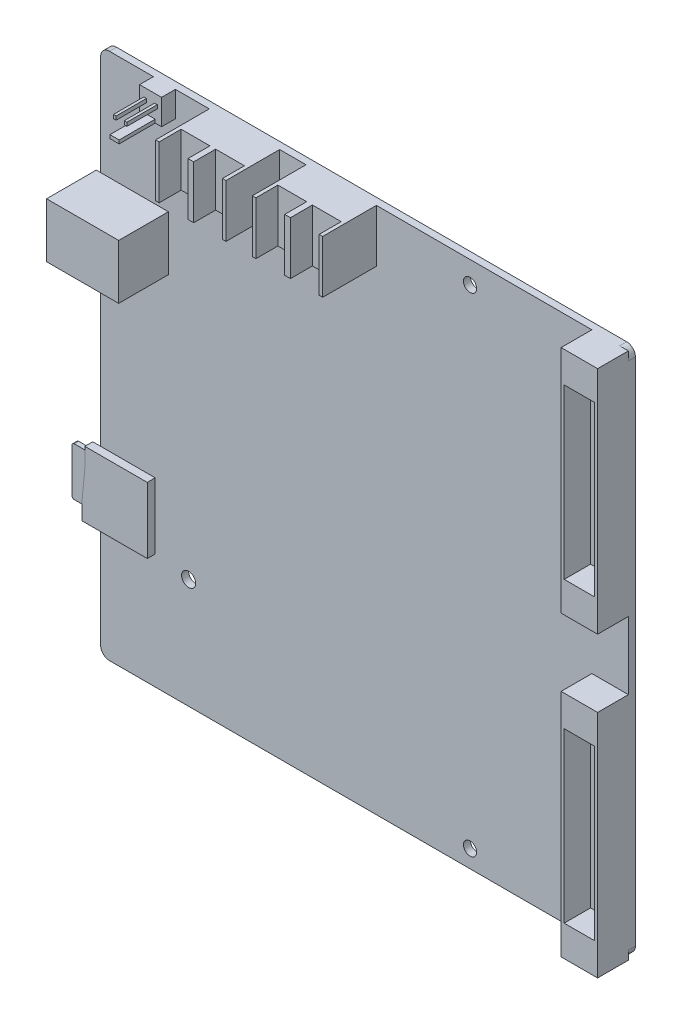
from build123d import *

# Parameters (mm, degrees)
SKETCH_1_R             = 1.5
EXTRUDE_1_DEPTH        = 1.6
SKETCH_2_W             = 16.4
SKETCH_2_H             = 12.4
EXTRUDE_2_DEPTH        = 11.3
SKETCH_3_W             = 3
SKETCH_3_H             = 5.4
CUT_EXTRUDE_1_DEPTH    = 9
EXTRUDE_3_DEPTH        = 1.8
SKETCH_5_W             = 1
SKETCH_5_H             = 11
EXTRUDE_4_DEPTH        = 3
FILLET_1_R             = 0.5
SKETCH_43_W            = 8.3
SKETCH_43_H            = 52.3
EXTRUDE_15_DEPTH       = 7
SKETCH_45_W            = 6.9
SKETCH_45_H            = 38.3
CUT_EXTRUDE_12_DEPTH   = 6
SKETCH_53_W            = 16
SKETCH_53_H            = 12
EXTRUDE_20_DEPTH       = 12.2
SKETCH_54_W            = 6.55
SKETCH_54_H            = 12
CUT_EXTRUDE_14_DEPTH   = 5
SKETCH_59_R            = 1.6
CUT_EXTRUDE_16_DEPTH   = 10
PATTERN_LINEAR_4_COUNT = 2
PATTERN_LINEAR_4_PITCH = 22
SKETCH_60_W            = 5
SKETCH_60_H            = 5.8
EXTRUDE_21_DEPTH       = 3.15
SKETCH_61_W            = 2.1
SKETCH_61_H            = 0.78
EXTRUDE_22_DEPTH       = 8.2
EXTRUDE_23_DEPTH       = 6.9
EXTRUDE_23_DEPTH_BACK  = 6
SKETCH_62_W            = 0.6
SKETCH_62_H            = 0.835930121


with BuildPart() as part:
    # 草图1 → 凸台-拉伸1 (new body)
    with BuildSketch(Plane.XY):
        with BuildLine():
            Line((58, -60), (-58, -60))
            ThreePointArc((-58, -60), (-59.414213562, -59.414213562), (-60, -58))
            Line((-60, -58), (-60, 58))
            ThreePointArc((-60, 58), (-59.414213562, 59.414213562), (-58, 60))
            Line((-58, 60), (58, 60))
            ThreePointArc((58, 60), (59.414213562, 59.414213562), (60, 58))
            Line((60, 58), (60, -58))
            ThreePointArc((60, -58), (59.414213562, -59.414213562), (58, -60))
        make_face()
        with Locations((24, 55)):
            Circle(SKETCH_1_R, mode=Mode.SUBTRACT)
        with Locations((24, -56)):
            Circle(SKETCH_1_R, mode=Mode.SUBTRACT)
    extrude(amount=EXTRUDE_1_DEPTH)

    # 草图2 → 凸台-拉伸2 (add)
    with BuildSketch(Plane.XY.offset(1.6)):
        with Locations((-52.8, 28.9)):
            Rectangle(SKETCH_2_W, SKETCH_2_H)
    extrude(amount=EXTRUDE_2_DEPTH)

    # 草图3 → 切除-拉伸1 (cut)
    with BuildSketch(Plane.ZY.offset(61)):
        Polygon((3, 33.7), (3, 24.1), (9.9, 24.1), (11.5, 25.7), (11.5, 32.1), (9.9, 33.7), align=None)
        with Locations((6.9, 28.9)):
            Rectangle(SKETCH_3_W, SKETCH_3_H, mode=Mode.SUBTRACT)
    extrude(amount=-CUT_EXTRUDE_1_DEPTH, mode=Mode.SUBTRACT)

    # 草图4 → 凸台-拉伸3 (add)
    with BuildSketch(Plane.XY.offset(1.6)):
        Polygon((-47.6, -18.8), (-47.6, -33.8), (-62.4, -33.8), (-62.4, -29.5), (-61.8, -23.188583942), (-61.8, -18.8), align=None)
    extrude(amount=EXTRUDE_3_DEPTH)

    # 草图5 → 凸台-拉伸4 (add)
    with BuildSketch(Plane.ZY.offset(61.8)):
        with Locations((2.8, -25.1)):
            Rectangle(SKETCH_5_W, SKETCH_5_H)
    extrude(amount=EXTRUDE_4_DEPTH)

    # 圆角1
    fillet_1_edges = [part.edges().sort_by_distance(p)[0] for p in [
        (-64.8, -19.6, 2.8),
        (-64.8, -30.6, 2.8),
    ]]
    fillet(fillet_1_edges, radius=FILLET_1_R)

    # 草图43 → 凸台-拉伸15 (add)
    with BuildSketch(Plane(origin=(66.890855613, 85.562649537, 1.6), x_dir=(1, 0, 0), z_dir=(0, 0, 1))):
        with Locations((-11.040855613, -51.712649537)):
            Rectangle(SKETCH_43_W, SKETCH_43_H)
        with Locations((-11.040855613, -119.412649537)):
            Rectangle(SKETCH_43_W, SKETCH_43_H)
    extrude(amount=EXTRUDE_15_DEPTH)

    # 草图45 → 切除-拉伸12 (cut)
    with BuildSketch(Plane(origin=(66.890855613, 85.562649537, 8.6), x_dir=(1, 0, 0), z_dir=(0, 0, 1))):
        with Locations((-11.040855613, -51.712649537)):
            Rectangle(SKETCH_45_W, SKETCH_45_H)
        with Locations((-11.040855613, -119.412649537)):
            Rectangle(SKETCH_45_W, SKETCH_45_H)
    extrude(amount=-CUT_EXTRUDE_12_DEPTH, mode=Mode.SUBTRACT)

    # 草图53 → 凸台-拉伸20 (add)
    with BuildSketch(Plane.XY.offset(1.6)):
        with Locations((-5.3, 54)):
            Rectangle(SKETCH_53_W, SKETCH_53_H)
    extrude_20 = extrude(amount=EXTRUDE_20_DEPTH)

    # 草图54 → 切除-拉伸14 (cut)
    with BuildSketch(Plane.XY.offset(13.8)):
        with Locations((-9.225, 54)):
            Rectangle(SKETCH_54_W, SKETCH_54_H)
        with Locations((-1.375, 54)):
            Rectangle(SKETCH_54_W, SKETCH_54_H)
    cut_extrude_14 = extrude(amount=-CUT_EXTRUDE_14_DEPTH, mode=Mode.SUBTRACT)

    # 草图59 → 切除-拉伸16 (cut)
    with BuildSketch(Plane.XY.offset(1.6)):
        with Locations((-40, -35)):
            Circle(SKETCH_59_R)
        with Locations((-40, 45)):
            Circle(SKETCH_59_R)
    extrude(amount=-CUT_EXTRUDE_16_DEPTH, mode=Mode.SUBTRACT)

    # 阵列(线性)4: 凸台-拉伸20, 切除-拉伸14 ×2
    with Locations(*[(-i * PATTERN_LINEAR_4_PITCH, 0, 0) for i in range(1, PATTERN_LINEAR_4_COUNT)]):
        add(extrude_20)
        add(cut_extrude_14, mode=Mode.SUBTRACT)

    # 草图60 → 凸台-拉伸21 (add)
    with BuildSketch(Plane.XY.offset(1.6)):
        with Locations((-45.5, 57.1)):
            Rectangle(SKETCH_60_W, SKETCH_60_H)
    extrude(amount=EXTRUDE_21_DEPTH)

    # 草图61 → 凸台-拉伸22 (add)
    with BuildSketch(Plane.XY.offset(4.75)):
        with Locations((-45.5, 54.59)):
            Rectangle(SKETCH_61_W, SKETCH_61_H)
    extrude(amount=EXTRUDE_22_DEPTH)

    # 草图62 → 凸台-拉伸23 (add, two sides: drawn at the far end of the back side and taken through both)
    with BuildSketch(Plane.XY.offset(4.75).offset(-EXTRUDE_23_DEPTH_BACK)):
        with Locations((-44.275, 57.657035773)):
            Rectangle(SKETCH_62_W, SKETCH_62_H)
        with Locations((-46.725, 57.657035773)):
            Rectangle(SKETCH_62_W, SKETCH_62_H)
    extrude(amount=EXTRUDE_23_DEPTH + EXTRUDE_23_DEPTH_BACK)


solid = part.part
